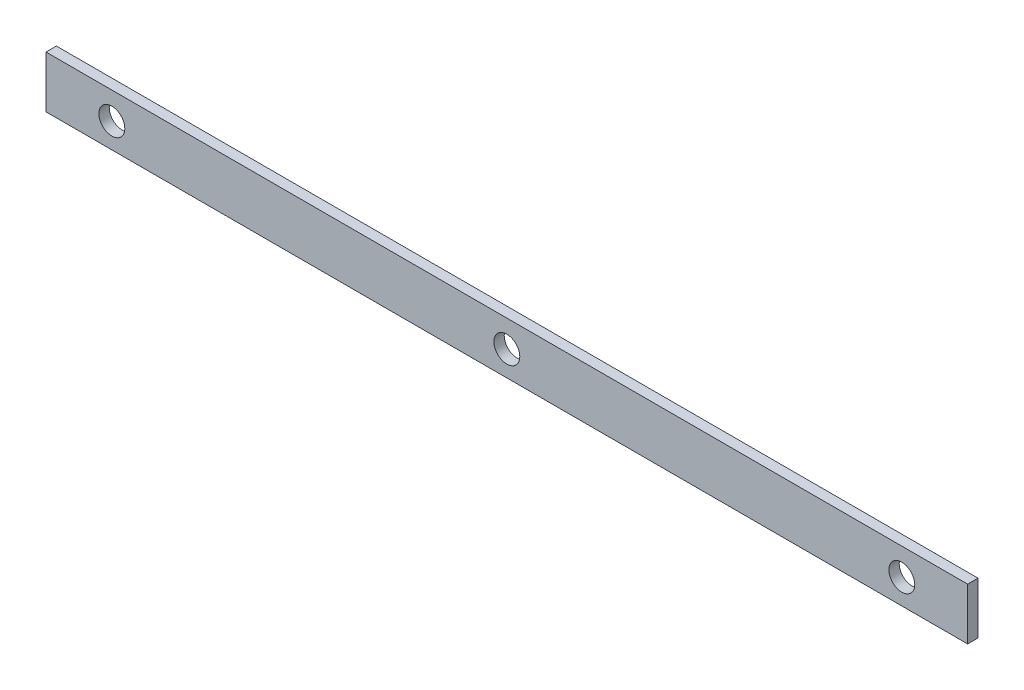
from build123d import *

# Parameters (mm, degrees)
SKETCH1_W                    = 177.8
SKETCH1_H                    = 10
BOSS_EXTRUDE1_DEPTH          = 2
F_5_0_5_DIAMETER_HOLE1_D     = 5
F_5_0_5_DIAMETER_HOLE1_DEPTH = 5
F_5_0_5_DIAMETER_HOLE1_TIP   = 1.502151548


with BuildPart() as part:
    # Sketch1 → Boss-Extrude1 (new body)
    with BuildSketch(Plane.XY):
        with Locations((43.423133199, 0.190336281)):
            Rectangle(SKETCH1_W, SKETCH1_H)
    extrude(amount=BOSS_EXTRUDE1_DEPTH)

    # Ø5.0 (5) Diameter Hole1
    with Locations(Plane.XY.offset(2)):
        with Locations((-32.776866801, 0), (43.423133199, 0), (119.623133199, 0)):
            Hole(F_5_0_5_DIAMETER_HOLE1_D / 2, depth=F_5_0_5_DIAMETER_HOLE1_DEPTH)
            with Locations((0, 0, -(F_5_0_5_DIAMETER_HOLE1_DEPTH + F_5_0_5_DIAMETER_HOLE1_TIP / 2))):  # 118° drill point
                Cone(0, F_5_0_5_DIAMETER_HOLE1_D / 2, F_5_0_5_DIAMETER_HOLE1_TIP, mode=Mode.SUBTRACT)


solid = part.part
